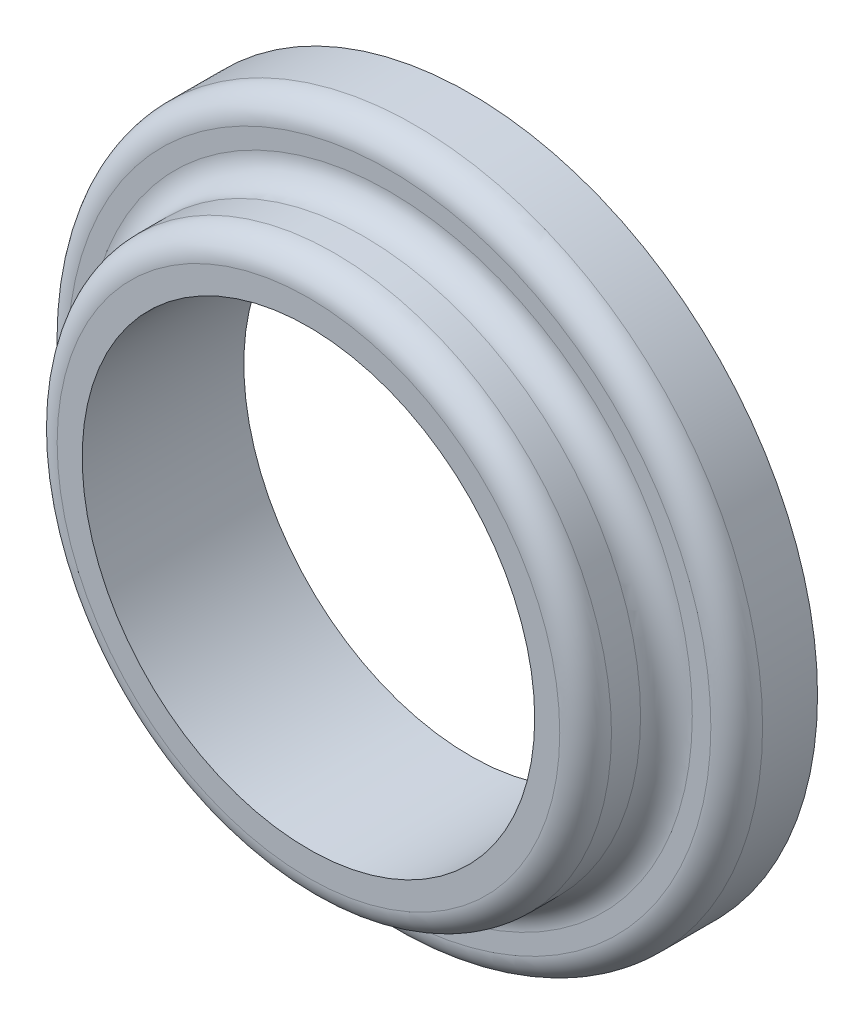
from build123d import *

# Parameters (mm, degrees)
SKETCH1_R           = 6.82625
SKETCH1_R_2         = 4.445
BOSS_EXTRUDE1_DEPTH = 1.5875
SKETCH2_R           = 5.445
SKETCH2_R_2         = 4.445
EXTRUDE_THIN1_DEPTH = 1.5875
FILLET1_R           = 0.508


with BuildPart() as part:
    # Sketch1 → Boss-Extrude1 (new body)
    with BuildSketch(Plane.XY):
        with Locations((-6.731, -165.7192297)):
            Circle(SKETCH1_R)
        with Locations((-6.731, -165.7192297)):
            Circle(SKETCH1_R_2, mode=Mode.SUBTRACT)
    extrude(amount=BOSS_EXTRUDE1_DEPTH)

    # Sketch2 → Extrude-Thin1 (add)
    with BuildSketch(Plane.XY.offset(1.5875)):
        with Locations((-6.731, -165.7192297)):
            Circle(SKETCH2_R)
        with Locations((-6.731, -165.7192297)):
            Circle(SKETCH2_R_2, mode=Mode.SUBTRACT)
    extrude(amount=EXTRUDE_THIN1_DEPTH)

    # Fillet1
    fillet1_edges = [part.edges().sort_by_distance(p)[0] for p in [
        (-12.176, -165.7192297, 3.175),
        (-12.176, -165.7192297, 1.5875),
        (-13.55725, -165.7192297, 1.5875),
    ]]
    fillet(fillet1_edges, radius=FILLET1_R)


solid = part.part
